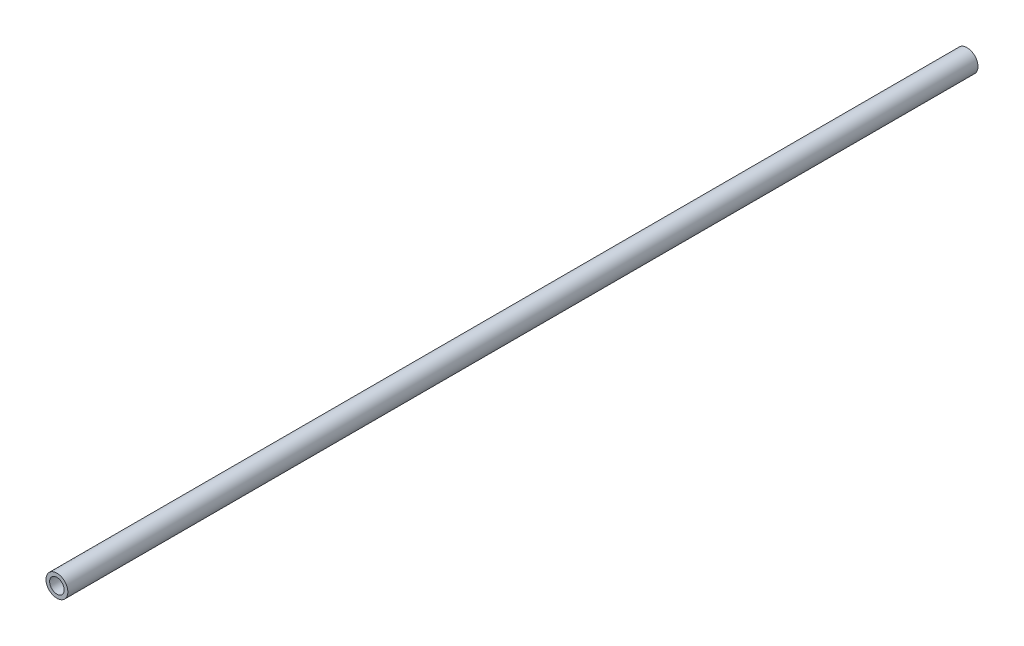
from build123d import *

# Parameters (mm, degrees)
SKETCH1_R           = 7.62
SKETCH1_R_2         = 5.08
BOSS_EXTRUDE1_DEPTH = 635


with BuildPart() as part:
    # Sketch1 → Boss-Extrude1 (new body)
    with BuildSketch(Plane.XY):
        Circle(SKETCH1_R)
        Circle(SKETCH1_R_2, mode=Mode.SUBTRACT)
    extrude(amount=BOSS_EXTRUDE1_DEPTH)


solid = part.part
